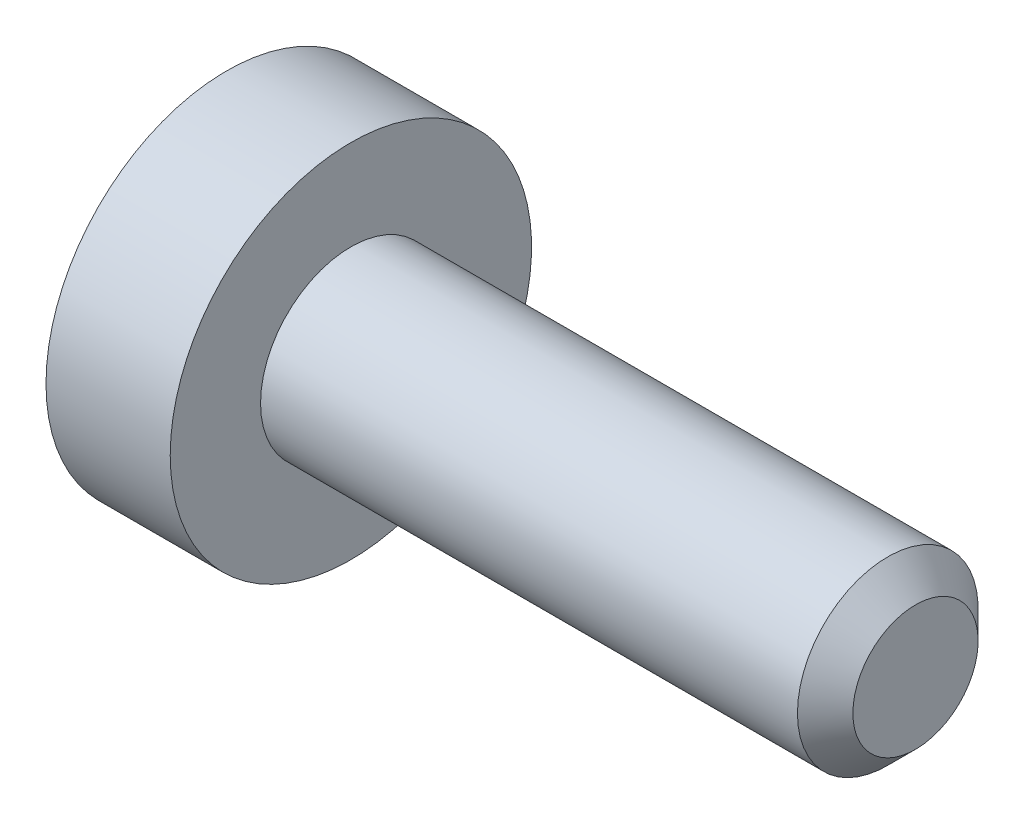
from build123d import *

# Parameters (mm, degrees)
SKETCH2_W          = 1.1
SKETCH2_H          = 1.6
CUT_EXTRUDE1_DEPTH = 1.2


with BuildPart() as part:
    # Sketch1 → Revolve1 (revolve)
    with BuildSketch(Plane.XY):
        Polygon((0, 0), (0, 0.8), (4.7545, 0.8), (5, 0.5545), (5, 0), align=None)
    revolve(axis=Axis((5, 0, 0), (-1, 0, 0)))

    # Sketch2 → Revolve2 (revolve)
    with BuildSketch(Plane.XY):
        with Locations((-0.55, 0.8)):
            Rectangle(SKETCH2_W, SKETCH2_H)
    revolve(axis=Axis((0, 0, 0), (-1, 0, 0)))

    # Sketch3 → Cut-Revolve1 (revolve, cut)
    with BuildSketch(Plane.XY):
        Polygon((-1.1, 0), (-1.1, 0.78), (-0.97, 0.65), (0.1, 0.65), (0.475277675, 0), align=None)
    revolve(axis=Axis((0.475277675, 0, 0), (-1, 0, 0)), mode=Mode.SUBTRACT)

    # Sketch4 → Cut-Extrude1 (cut)
    with BuildSketch(Plane(origin=(-1.1, 0, 0), x_dir=(0, 0, -1), z_dir=(1, 0, 0))):
        Polygon((-0.65, -0.375277675), (0, -0.75055535), (0.65, -0.375277675), (0.65, 0.375277675), (0, 0.75055535), (-0.65, 0.375277675), align=None)
    extrude(amount=CUT_EXTRUDE1_DEPTH, mode=Mode.SUBTRACT)


solid = part.part
